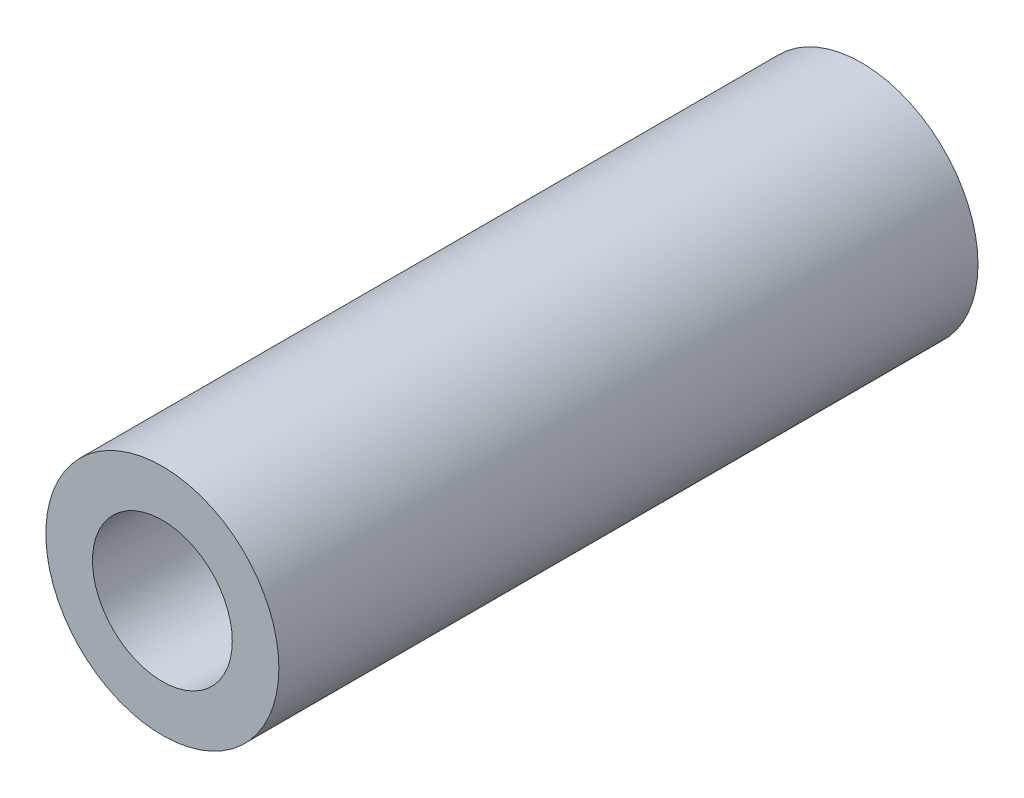
from build123d import *

# Parameters (mm, degrees)
SKETCH1_R          = 7.9375
SKETCH1_R_2        = 3.2004
EXTRUDE1_DEPTH     = 25.4
SKETCH5_R          = 7.9375
SKETCH5_R_2        = 3.2004
CUT_EXTRUDE1_DEPTH = 3.175
SKETCH6_R          = 4.7625
CUT_EXTRUDE2_DEPTH = 48.625


with BuildPart() as part:
    # Sketch1 → Extrude1 (new body, symmetric)
    with BuildSketch(Plane.XY):
        Circle(SKETCH1_R)
        Circle(SKETCH1_R_2, mode=Mode.SUBTRACT)
    extrude(amount=EXTRUDE1_DEPTH, both=True)

    # Sketch5 → Cut-Extrude1 (cut)
    with BuildSketch(Plane.XY.offset(25.4)):
        Circle(SKETCH5_R)
        Circle(SKETCH5_R_2, mode=Mode.SUBTRACT)
    extrude(amount=-CUT_EXTRUDE1_DEPTH, mode=Mode.SUBTRACT)

    # Sketch6 → Cut-Extrude2 (cut, through all)
    with BuildSketch(Plane.XY.offset(22.225)):
        Circle(SKETCH6_R)
    extrude(amount=-CUT_EXTRUDE2_DEPTH, mode=Mode.SUBTRACT)


solid = part.part
